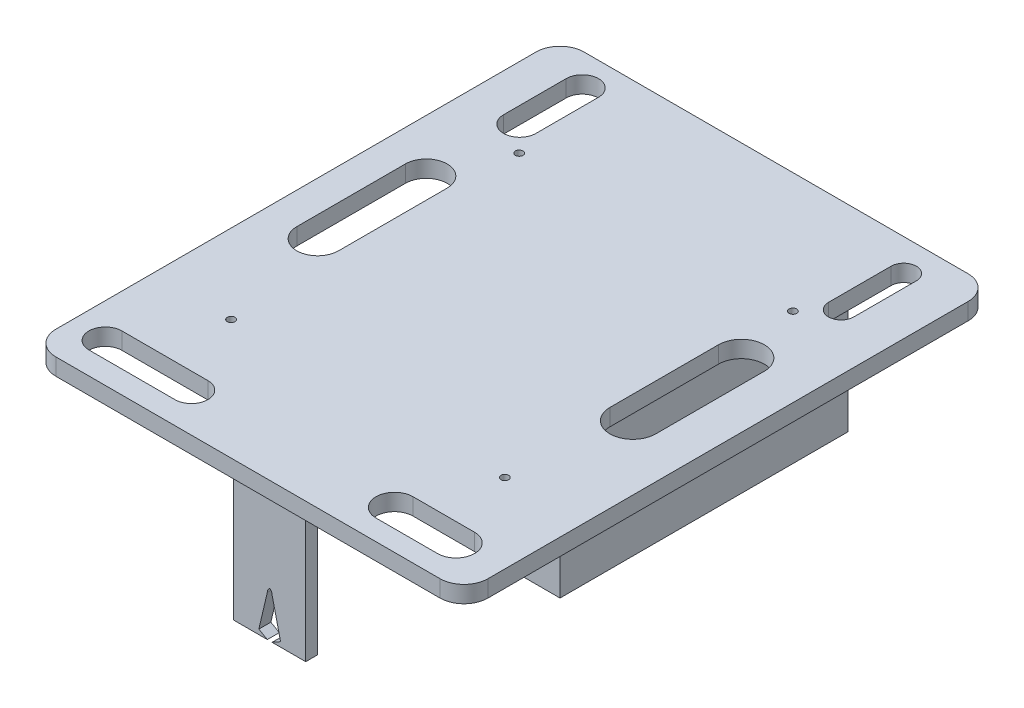
from build123d import *

# Parameters (mm, degrees)
SKETCH_1_R          = 1.6
EXTRUDE_1_DEPTH     = 7
SKETCH_2_W          = 90
SKETCH_2_H          = 120
SKETCH_2_W_2        = 80
SKETCH_2_H_2        = 110
EXTRUDE_2_DEPTH     = 60
SKETCH_3_W          = 56
SKETCH_3_H          = 36
SKETCH_3_W_2        = 50
SKETCH_3_H_2        = 30
EXTRUDE_3_DEPTH     = 10
SKETCH_5_W          = 56
SKETCH_5_H          = 3
EXTRUDE_4_DEPTH     = 20
SKETCH_6_W          = 30
SKETCH_6_H          = 5
EXTRUDE_5_DEPTH     = 60
CUT_EXTRUDE_1_DEPTH = 10
EXTRUDE_6_DEPTH     = 5
CUT_EXTRUDE_2_DEPTH = 10
CUT_EXTRUDE_3_DEPTH = 10
CUT_EXTRUDE_4_DEPTH = 10


with BuildPart() as part:
    # 草图1 → 凸台-拉伸1 (new body)
    with BuildSketch(Plane(origin=(0, 0, 0), x_dir=(1, 0, 0), z_dir=(0, 1, 0))):
        with BuildLine():
            Line((-85.25974026, 139.090909091), (74.74025974, 139.090909091))
            ThreePointArc((74.74025974, 139.090909091), (81.811327552, 136.161976903), (84.74025974, 129.090909091))
            Line((84.74025974, 129.090909091), (84.74025974, -70.909090909))
            ThreePointArc((84.74025974, -70.909090909), (81.811327552, -77.980158721), (74.74025974, -80.909090909))
            Line((74.74025974, -80.909090909), (-85.25974026, -80.909090909))
            ThreePointArc((-85.25974026, -80.909090909), (-92.330808072, -77.980158721), (-95.25974026, -70.909090909))
            Line((-95.25974026, -70.909090909), (-95.25974026, 129.090909091))
            ThreePointArc((-95.25974026, 129.090909091), (-92.330808072, 136.161976903), (-85.25974026, 139.090909091))
        make_face()
        with Locations((-62.25974026, 89.090909091)):
            Circle(SKETCH_1_R, mode=Mode.SUBTRACT)
        with Locations((51.74025974, 89.090909091)):
            Circle(SKETCH_1_R, mode=Mode.SUBTRACT)
        with Locations((-62.25974026, -30.909090909)):
            Circle(SKETCH_1_R, mode=Mode.SUBTRACT)
        with Locations((51.74025974, -30.909090909)):
            Circle(SKETCH_1_R, mode=Mode.SUBTRACT)
    extrude(amount=EXTRUDE_1_DEPTH)

    # 草图2 → 凸台-拉伸2 (add)
    with BuildSketch(Plane.XZ):
        with Locations((-5.25974026, -64.090909091)):
            Rectangle(SKETCH_2_W, SKETCH_2_H)
        with Locations((-5.25974026, -64.090909091)):
            Rectangle(SKETCH_2_W_2, SKETCH_2_H_2, mode=Mode.SUBTRACT)
    extrude(amount=EXTRUDE_2_DEPTH)

    # 草图3 → 凸台-拉伸3 (add)
    with BuildSketch(Plane.XZ):
        with Locations((-5.25974026, 22.137368895)):
            Rectangle(SKETCH_3_W, SKETCH_3_H)
        with Locations((-5.25974026, 22.137368895)):
            Rectangle(SKETCH_3_W_2, SKETCH_3_H_2, mode=Mode.SUBTRACT)
    extrude(amount=EXTRUDE_3_DEPTH)

    # 草图5 → 凸台-拉伸4 (add)
    with BuildSketch(Plane.XZ.offset(10)):
        with Locations((-5.25974026, 5.637368895)):
            Rectangle(SKETCH_5_W, SKETCH_5_H)
    extrude(amount=EXTRUDE_4_DEPTH)

    # 草图6 → 凸台-拉伸5 (add)
    with BuildSketch(Plane.XZ):
        with Locations((-5.25974026, 69.33277689)):
            Rectangle(SKETCH_6_W, SKETCH_6_H)
    extrude(amount=EXTRUDE_5_DEPTH)

    # 草图8 → 切除-拉伸1 (cut)
    with BuildSketch(Plane.XY.offset(71.83277689)):
        with BuildLine():
            Line((-6.25974026, -43), (-10.25974026, -60))
            Line((-10.25974026, -60), (-0.25974026, -60))
            Line((-0.25974026, -60), (-4.25974026, -43))
            ThreePointArc((-4.25974026, -43), (-4.523672282, -41.881966011), (-5.25974026, -41))
            ThreePointArc((-5.25974026, -41), (-5.995808237, -41.881966011), (-6.25974026, -43))
        make_face()
    extrude(amount=-CUT_EXTRUDE_1_DEPTH, mode=Mode.SUBTRACT)

    # 草图9 → 凸台-拉伸6 (add)
    with BuildSketch(Plane.XY.offset(71.83277689)):
        Polygon((-6.25974026, -60), (-9.789152024, -58), (-10.25974026, -60), align=None)
        Polygon((-4.25974026, -60), (-0.25974026, -60), (-0.730328495, -58), align=None)
    extrude(amount=-EXTRUDE_6_DEPTH)

    # 草图10 → 切除-拉伸2 (cut)
    with BuildSketch(Plane.XZ):
        with BuildLine():
            Line((-64.659020205, -16.259764427), (-64.659020205, -61.488758584))
            ThreePointArc((-64.659020205, -61.488758584), (-73.36978945, -70.199527829), (-82.080558695, -61.488758584))
            Line((-82.080558695, -61.488758584), (-82.080558695, -16.259764427))
            ThreePointArc((-82.080558695, -16.259764427), (-73.36978945, -7.548995182), (-64.659020205, -16.259764427))
        make_face()
        with BuildLine():
            Line((67.459227113, -16.259764427), (67.459227113, -61.488758584))
            ThreePointArc((67.459227113, -61.488758584), (57.906863547, -71.04112215), (48.354499981, -61.488758584))
            Line((48.354499981, -61.488758584), (48.354499981, -16.259764427))
            ThreePointArc((48.354499981, -16.259764427), (57.906863547, -6.707400861), (67.459227113, -16.259764427))
        make_face()
    extrude(amount=-CUT_EXTRUDE_2_DEPTH, mode=Mode.SUBTRACT)

    # 草图11 → 切除-拉伸3 (cut)
    with BuildSketch(Plane.XZ):
        with BuildLine():
            Line((-80.892767317, 71.523985845), (-45.044601578, 71.523985845))
            ThreePointArc((-45.044601578, 71.523985845), (-38.176495058, 64.655879325), (-45.044601578, 57.787772805))
            Line((-45.044601578, 57.787772805), (-80.892767317, 57.787772805))
            ThreePointArc((-80.892767317, 57.787772805), (-87.760873837, 64.655879325), (-80.892767317, 71.523985845))
        make_face()
        with BuildLine():
            Line((39.550368976, 72.361559811), (65.180132332, 72.361559811))
            ThreePointArc((65.180132332, 72.361559811), (72.885812818, 64.655879325), (65.180132332, 56.950198839))
            Line((65.180132332, 56.950198839), (39.550368976, 56.950198839))
            ThreePointArc((39.550368976, 56.950198839), (31.84468849, 64.655879325), (39.550368976, 72.361559811))
        make_face()
    extrude(amount=-CUT_EXTRUDE_3_DEPTH, mode=Mode.SUBTRACT)

    # 草图12 → 切除-拉伸4 (cut)
    with BuildSketch(Plane.XZ):
        with BuildLine():
            Line((-65.903935016, -99.695986078), (-65.903935016, -125.770060152))
            ThreePointArc((-65.903935016, -125.770060152), (-72.642178878, -132.508304014), (-79.38042274, -125.770060152))
            Line((-79.38042274, -125.770060152), (-79.38042274, -99.695986078))
            ThreePointArc((-79.38042274, -99.695986078), (-72.642178878, -92.957742216), (-65.903935016, -99.695986078))
        make_face()
        with BuildLine():
            Line((66.517205225, -99.695986078), (66.517205225, -125.770060152))
            ThreePointArc((66.517205225, -125.770060152), (61.243796985, -131.043468392), (55.970388746, -125.770060152))
            Line((55.970388746, -125.770060152), (55.970388746, -99.695986078))
            ThreePointArc((55.970388746, -99.695986078), (61.243796985, -94.422577838), (66.517205225, -99.695986078))
        make_face()
    extrude(amount=-CUT_EXTRUDE_4_DEPTH, mode=Mode.SUBTRACT)


solid = part.part
